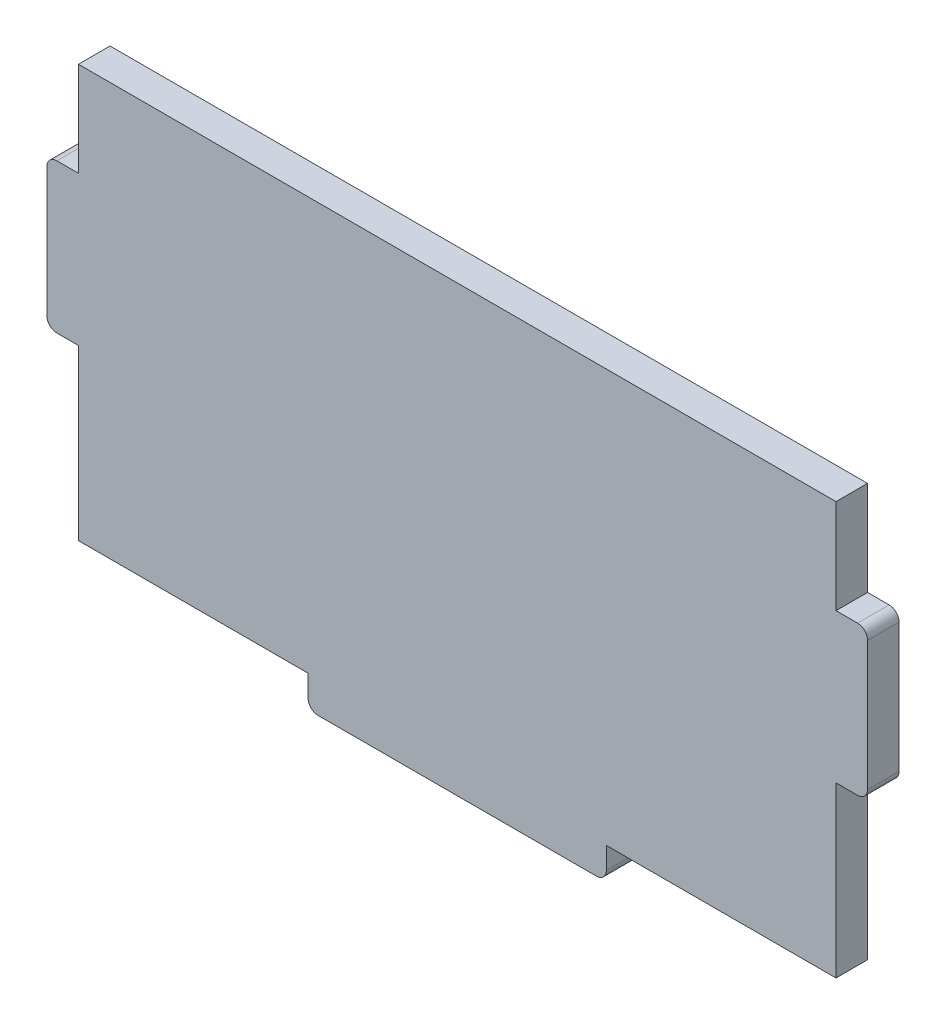
from build123d import *

# Parameters (mm, degrees)
SKETCH1_W           = 76.2
SKETCH1_H           = 41.5
BOSS_EXTRUDE1_DEPTH = 3.175
SKETCH2_W           = 3.175
SKETCH2_H           = 15
BOSS_EXTRUDE2_DEPTH = 3.175
SKETCH4_W           = 30
SKETCH4_H           = 3.175
BOSS_EXTRUDE4_DEPTH = 3.175
SKETCH5_W           = 3.175
SKETCH5_H           = 15
BOSS_EXTRUDE5_DEPTH = 3.175
FILLET1_R           = 1


with BuildPart() as part:
    # Sketch1 → Boss-Extrude1 (new body)
    with BuildSketch(Plane.XY):
        Rectangle(SKETCH1_W, SKETCH1_H)
    extrude(amount=BOSS_EXTRUDE1_DEPTH)

    # Sketch2 → Boss-Extrude2 (add)
    with BuildSketch(Plane(origin=(38.1, 0, 0), x_dir=(0, 0, -1), z_dir=(1, 0, 0))):
        with Locations((-1.5875, 3.75)):
            Rectangle(SKETCH2_W, SKETCH2_H)
    extrude(amount=BOSS_EXTRUDE2_DEPTH)

    # Sketch4 → Boss-Extrude4 (add)
    with BuildSketch(Plane.XZ.offset(20.75)):
        with Locations((0, 1.5875)):
            Rectangle(SKETCH4_W, SKETCH4_H)
    extrude(amount=BOSS_EXTRUDE4_DEPTH)

    # Sketch5 → Boss-Extrude5 (add)
    with BuildSketch(Plane.ZY.offset(38.1)):
        with Locations((1.5875, 3.75)):
            Rectangle(SKETCH5_W, SKETCH5_H)
    extrude(amount=BOSS_EXTRUDE5_DEPTH)

    # Fillet1
    fillet1_edges = [part.edges().sort_by_distance(p)[0] for p in [
        (41.275, -3.75, 1.5875),
        (41.275, 11.25, 1.5875),
        (-15, -23.925, 1.5875),
        (15, -23.925, 1.5875),
        (-41.275, -3.75, 1.5875),
        (-41.275, 11.25, 1.5875),
    ]]
    fillet(fillet1_edges, radius=FILLET1_R)


solid = part.part
